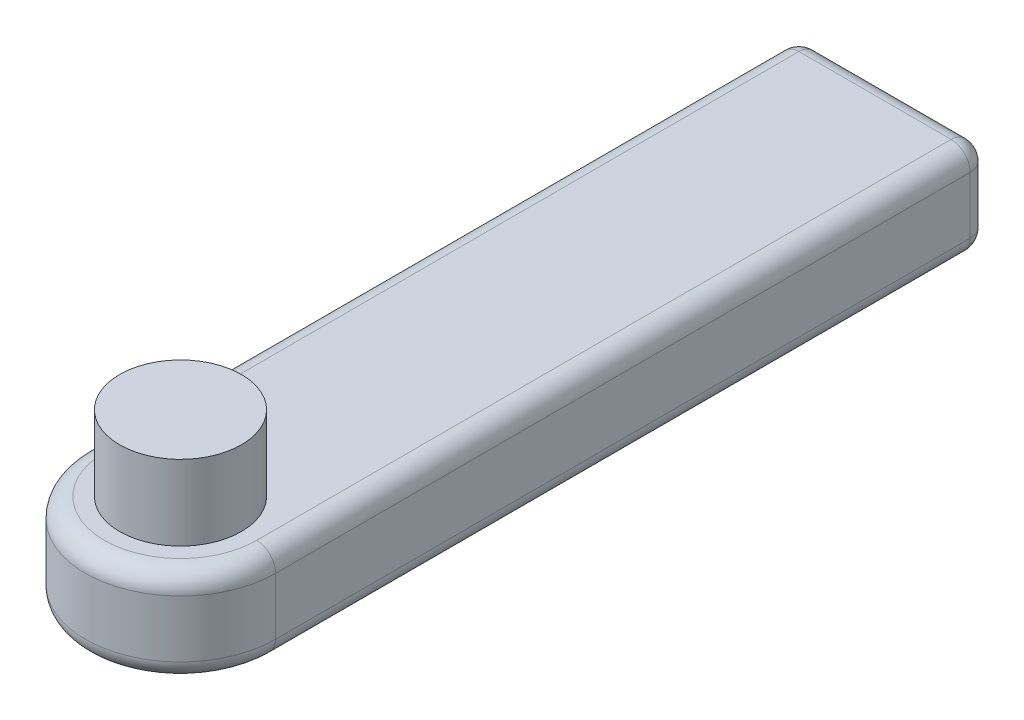
from build123d import *

# Parameters (mm, degrees)
SKETCH2_R           = 10
BOSS_EXTRUDE2_DEPTH = 10
SKETCH3_R           = 6.4
BOSS_EXTRUDE3_DEPTH = 7.9
SKETCH4_R           = 2.75
CUT_EXTRUDE1_DEPTH  = 5
FILLET1_R           = 2


with BuildPart() as part:
    # Sketch2 → Boss-Extrude2 (new body)
    with BuildSketch(Plane(origin=(0, 0, 0), x_dir=(1, 0, 0), z_dir=(0, 1, 0))):
        Circle(SKETCH2_R)
        with BuildLine():
            Line((-10, 75), (-10, 0))
            ThreePointArc((-10, 0), (0, 10), (10, 0))
            Line((10, 0), (10, 75))
            Line((10, 75), (-10, 75))
        make_face()
    extrude(amount=BOSS_EXTRUDE2_DEPTH)

    # Sketch3 → Boss-Extrude3 (add)
    with BuildSketch(Plane(origin=(0, 10, 0), x_dir=(1, 0, 0), z_dir=(0, 1, 0))):
        Circle(SKETCH3_R)
    extrude(amount=BOSS_EXTRUDE3_DEPTH)

    # Sketch4 → Cut-Extrude1 (cut)
    with BuildSketch(Plane(origin=(0, 0, -75), x_dir=(-1, 0, 0), z_dir=(0, 0, -1))):
        with Locations((0, 5)):
            Circle(SKETCH4_R)
    extrude(amount=-CUT_EXTRUDE1_DEPTH, mode=Mode.SUBTRACT)

    # Fillet1
    fillet1_edges = [part.edges().sort_by_distance(p)[0] for p in [
        (10, 10, -37.5),
        (0, 10, -75),
        (-10, 10, -37.5),
        (0, 10, 10),
        (-10, 0, -37.5),
        (0, 0, -75),
        (10, 0, -37.5),
        (0, 0, 10),
        (-10, 5, -75),
        (10, 5, -75),
    ]]
    fillet(fillet1_edges, radius=FILLET1_R)


solid = part.part
